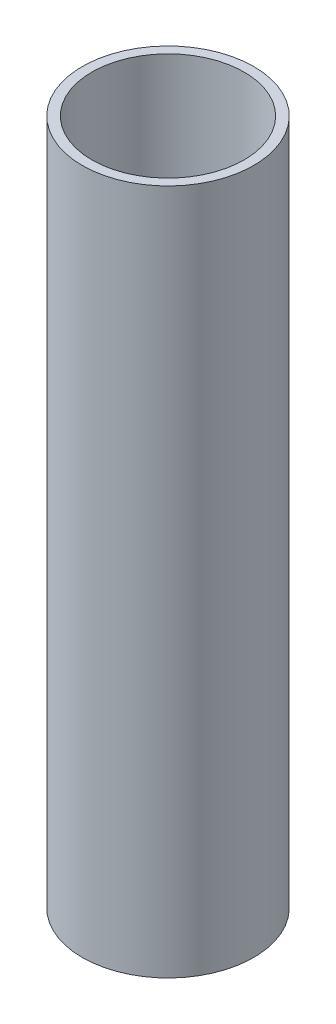
from build123d import *

# Parameters (mm, degrees)
SKETCH1_R           = 6.35
SKETCH1_R_2         = 5.6388
BOSS_EXTRUDE1_DEPTH = 50.8


with BuildPart() as part:
    # Sketch1 → Boss-Extrude1 (new body)
    with BuildSketch(Plane(origin=(0, 0, 0), x_dir=(1, 0, 0), z_dir=(0, 1, 0))):
        Circle(SKETCH1_R)
        Circle(SKETCH1_R_2, mode=Mode.SUBTRACT)
    extrude(amount=BOSS_EXTRUDE1_DEPTH)


solid = part.part
